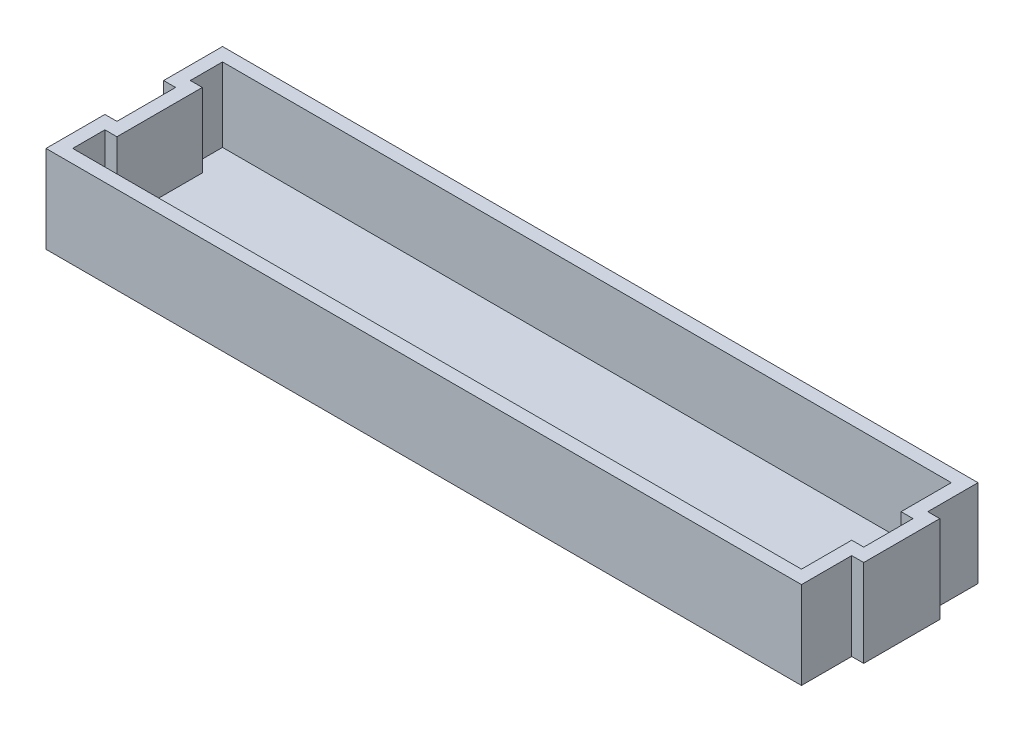
from build123d import *

# Parameters (mm, degrees)
BOSS_EXTRUDE1_DEPTH = 6.55
SHELL1_T            = -1


with BuildPart() as part:
    # Sketch1 → Boss-Extrude1 (new body)
    with BuildSketch(Plane(origin=(0, 0, 0), x_dir=(1, 0, 0), z_dir=(0, 1, 0))):
        Polygon((28.31, 6.615), (28.31, 2.85), (29.21, 2.85), (29.21, -2.85), (28.31, -2.85), (28.31, -6.615), (-28.31, -6.615), (-28.31, -2.2), (-27.41, -2.2), (-27.41, 2.2), (-28.31, 2.2), (-28.31, 6.615), align=None)
    extrude(amount=BOSS_EXTRUDE1_DEPTH)

    # Shell1
    shell1_openings = [part.faces().sort_by_distance(p)[0] for p in [
        (0.3, 6.55, 0),
    ]]
    offset(amount=SHELL1_T, openings=shell1_openings, kind=Kind.INTERSECTION)


solid = part.part
